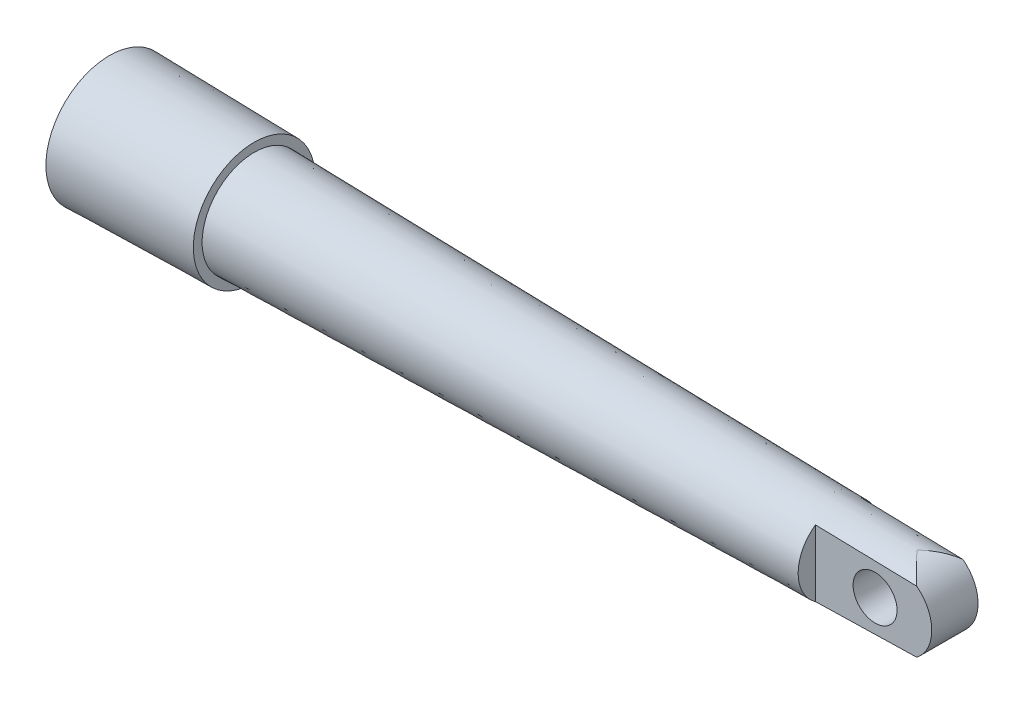
from build123d import *

# Parameters (mm, degrees)
BOSS_EXTRUDE2_DEPTH = 5
SKETCH7_R           = 4.75
CUT_EXTRUDE1_DEPTH  = 19.75
SKETCH8_R           = 5
CUT_EXTRUDE2_DEPTH  = 132.5


with BuildPart() as part:
    # Sketch1 → Revolve2 (revolve)
    with BuildSketch(Plane.XY):
        Polygon((157.5, 0), (0, 0), (0, 13.75), (31.25, 13.15), (31.25, 11.25), (157.5, 8.75), align=None)
    revolve(axis=Axis((157.5, 0, 0), (-1, 0, 0)))

    # Sketch2 → Boss-Extrude2 (add, symmetric)
    with BuildSketch(Plane.XY):
        with BuildLine():
            Line((157.5, 8.75), (174.296707174, 8.417391937))
            ThreePointArc((174.296707174, 8.417391937), (182.618377126, 0), (174.296707174, -8.417391937))
            Line((174.296707174, -8.417391937), (157.5, -8.75))
            Line((157.5, -8.75), (157.5, 8.75))
        make_face()
    extrude(amount=BOSS_EXTRUDE2_DEPTH, both=True)

    # Sketch6 → Cut-Revolve1 (revolve, cut)
    with BuildSketch(Plane.XY):
        Polygon((157.5, 8.75), (157.5, 12.5), (189.266018866, 12.5), (189.266018866, 8.120969923), align=None)
    revolve(axis=Axis((157.5, 0, 0), (1, 0, 0)), mode=Mode.SUBTRACT)

    # Sketch7 → Cut-Extrude1 (cut, through all)
    with BuildSketch(Plane.XY.offset(5)):
        with Locations((170.368377126, 0)):
            Circle(SKETCH7_R)
    extrude(amount=-CUT_EXTRUDE1_DEPTH, mode=Mode.SUBTRACT)

    # Sketch8 → Cut-Extrude2 (cut)
    with BuildSketch(Plane.ZY):
        Circle(SKETCH8_R)
    extrude(amount=-CUT_EXTRUDE2_DEPTH, mode=Mode.SUBTRACT)


solid = part.part
